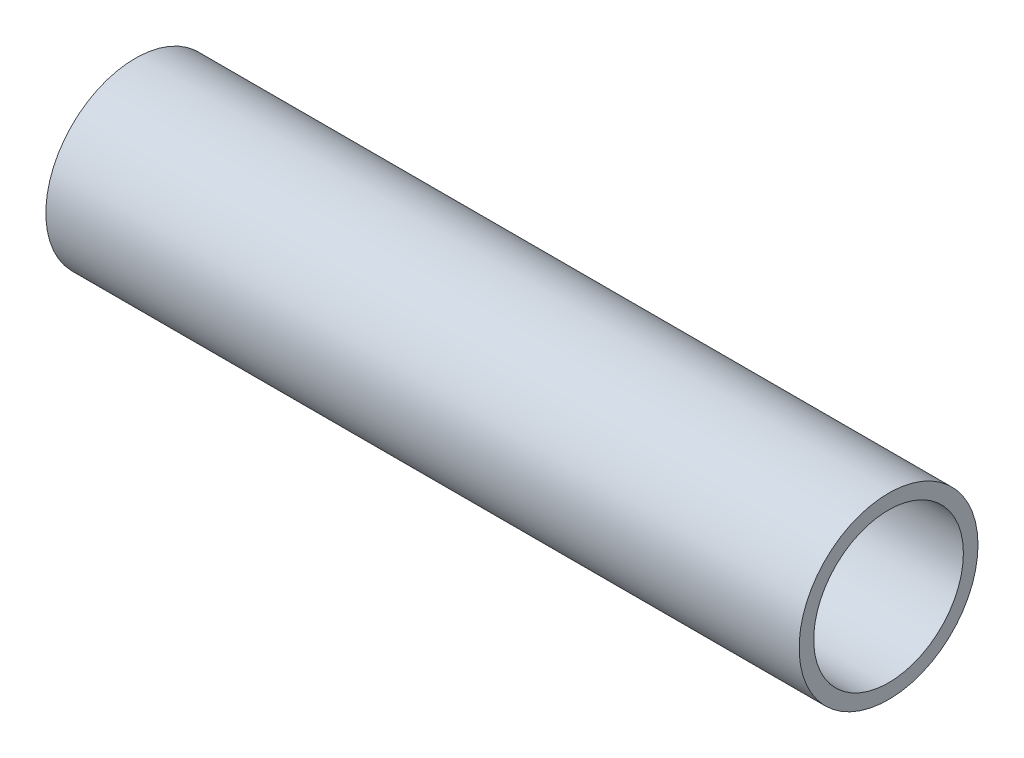
from build123d import *

# Parameters (mm, degrees)
SKETCH1_R           = 24.13
SKETCH1_R_2         = 20.193
BOSS_EXTRUDE1_DEPTH = 203.2


with BuildPart() as part:
    # Sketch1 → Boss-Extrude1 (new body)
    with BuildSketch(Plane(origin=(0, 0, 0), x_dir=(0, 0, -1), z_dir=(1, 0, 0))):
        Circle(SKETCH1_R)
        Circle(SKETCH1_R_2, mode=Mode.SUBTRACT)
    extrude(amount=BOSS_EXTRUDE1_DEPTH)


solid = part.part
